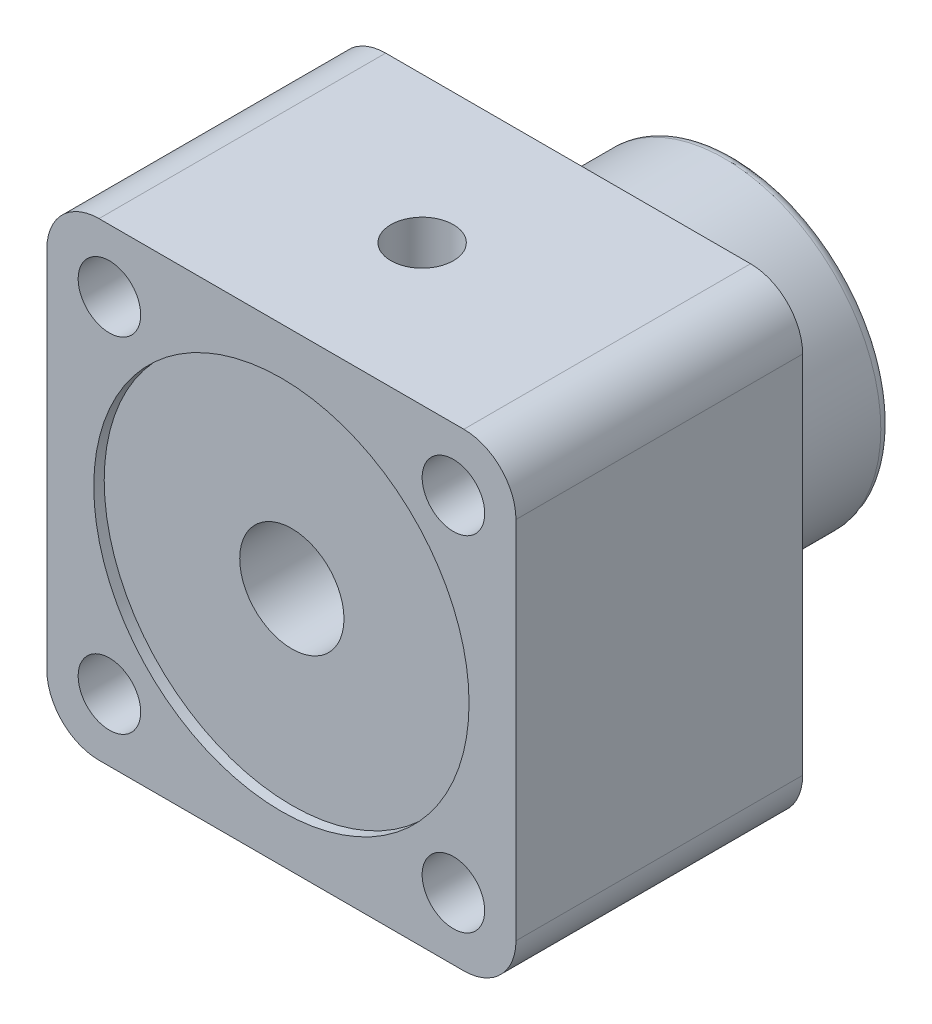
from build123d import *

# Parameters (mm, degrees)
SKETCH1_R           = 3
BOSS_EXTRUDE1_DEPTH = 27.5
SKETCH3_R           = 18
CUT_EXTRUDE1_DEPTH  = 1
SKETCH4_R           = 5
CUT_EXTRUDE2_DEPTH  = 28.5
SKETCH5_R           = 15
SKETCH5_R_2         = 5
BOSS_EXTRUDE2_DEPTH = 16
FILLET1_R           = 1
CUT_EXTRUDE3_REACH  = 47
SKETCH6_R           = 3


with BuildPart() as part:
    # Sketch1 → Boss-Extrude1 (new body)
    with BuildSketch(Plane.XY):
        with BuildLine():
            Line((0, 40), (0, 5))
            ThreePointArc((0, 5), (-1.464466094, 1.464466094), (-5, 0))
            Line((-5, 0), (-40, 0))
            ThreePointArc((-40, 0), (-43.535533906, 1.464466094), (-45, 5))
            Line((-45, 5), (-45, 40))
            ThreePointArc((-45, 40), (-43.535533906, 43.535533906), (-40, 45))
            Line((-40, 45), (-5, 45))
            ThreePointArc((-5, 45), (-1.464466094, 43.535533906), (0, 40))
        make_face()
        with Locations((-6, 39)):
            Circle(SKETCH1_R, mode=Mode.SUBTRACT)
        with Locations((-6, 6)):
            Circle(SKETCH1_R, mode=Mode.SUBTRACT)
        with Locations((-39, 6)):
            Circle(SKETCH1_R, mode=Mode.SUBTRACT)
        with Locations((-39, 39)):
            Circle(SKETCH1_R, mode=Mode.SUBTRACT)
    extrude(amount=BOSS_EXTRUDE1_DEPTH)

    # Sketch3 → Cut-Extrude1 (cut)
    with BuildSketch(Plane.XY.offset(27.5)):
        with Locations((-22.5, 22.5)):
            Circle(SKETCH3_R)
    extrude(amount=-CUT_EXTRUDE1_DEPTH, mode=Mode.SUBTRACT)

    # Sketch4 → Cut-Extrude2 (cut, through all)
    with BuildSketch(Plane(origin=(0, 0, 0), x_dir=(-1, 0, 0), z_dir=(0, 0, -1))):
        with Locations((22.5, 22.5)):
            Circle(SKETCH4_R)
    extrude(amount=-CUT_EXTRUDE2_DEPTH, mode=Mode.SUBTRACT)

    # Sketch5 → Boss-Extrude2 (add)
    with BuildSketch(Plane(origin=(0, 0, 0), x_dir=(-1, 0, 0), z_dir=(0, 0, -1))):
        with Locations((22.5, 22.5)):
            Circle(SKETCH5_R)
        with Locations((22.5, 22.5)):
            Circle(SKETCH5_R_2, mode=Mode.SUBTRACT)
    extrude(amount=BOSS_EXTRUDE2_DEPTH)

    # Fillet1
    fillet1_edges = [part.edges().sort_by_distance(p)[0] for p in [
        (-7.5, 22.5, -16),
    ]]
    fillet(fillet1_edges, radius=FILLET1_R)

    # Sketch6 → Cut-Extrude3 (cut, up to next)
    with BuildSketch(Plane(origin=(0, 45, 0), x_dir=(1, 0, 0), z_dir=(0, 1, 0)), mode=Mode.PRIVATE) as cut_extrude3_sk1:
        with Locations((-22.5, -14)):
            Circle(SKETCH6_R)
    cut_extrude3_tool1 = extrude(cut_extrude3_sk1.sketch, amount=-CUT_EXTRUDE3_REACH, mode=Mode.PRIVATE) & part.part
    add(cut_extrude3_tool1.solids().sort_by_distance((-22.5, 45, 14))[0], mode=Mode.SUBTRACT)


solid = part.part
